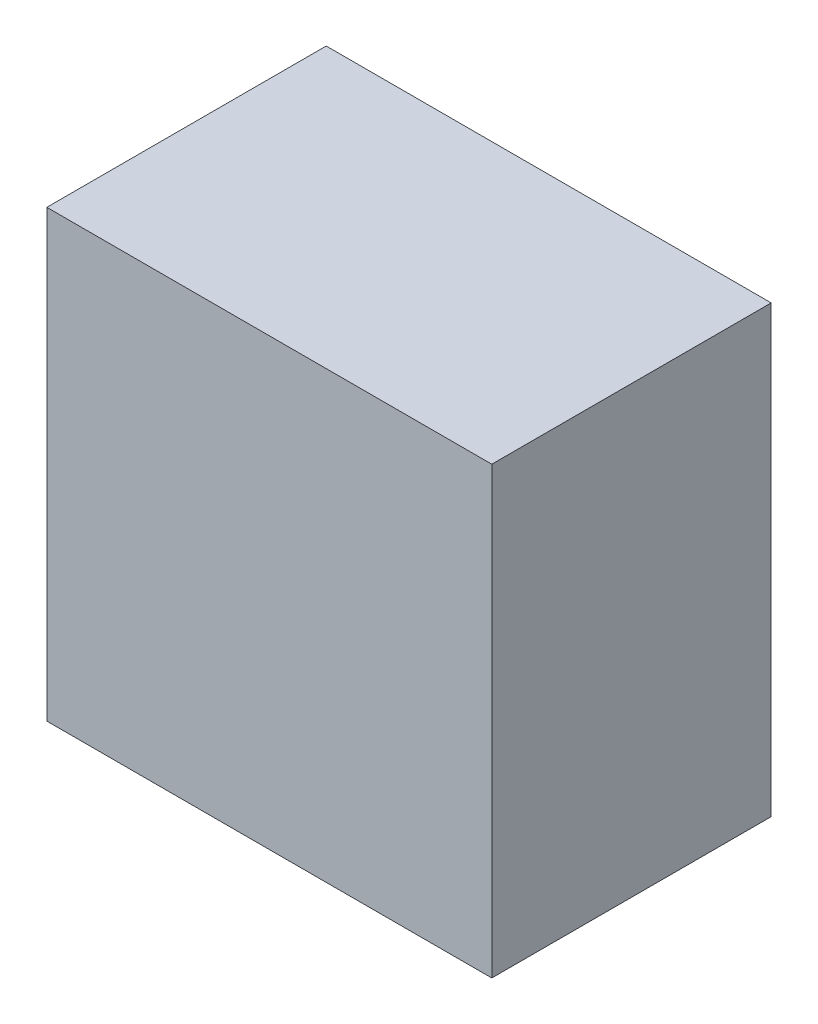
from build123d import *

# Parameters (mm, degrees)
SKETCH1_W           = 43
SKETCH1_H           = 43
BOSS_EXTRUDE1_DEPTH = 27


with BuildPart() as part:
    # Sketch1 → Boss-Extrude1 (new body)
    with BuildSketch(Plane.XY):
        Rectangle(SKETCH1_W, SKETCH1_H)
    extrude(amount=BOSS_EXTRUDE1_DEPTH)


solid = part.part
